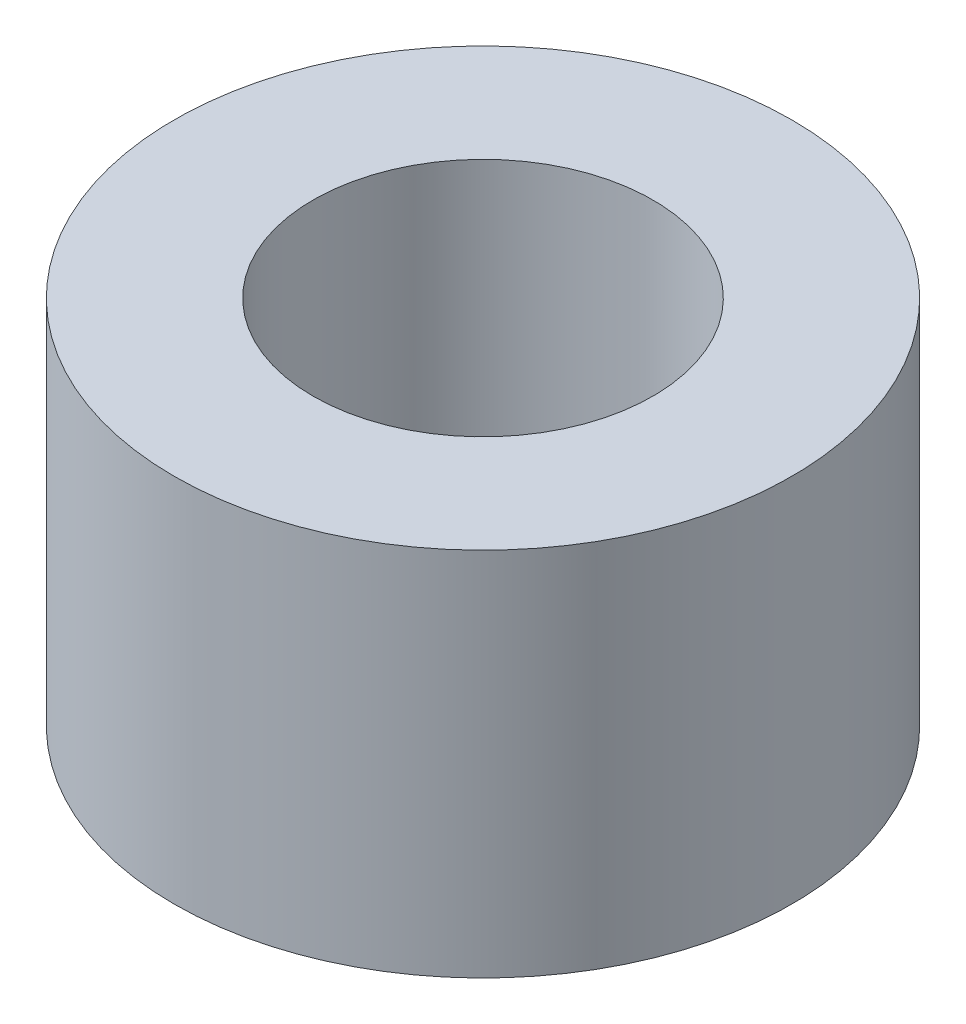
from build123d import *

# Parameters (mm, degrees)
SKETCH1_R           = 3.96875
SKETCH1_R_2         = 2.1844
BOSS_EXTRUDE1_DEPTH = 4.7625


with BuildPart() as part:
    # Sketch1 → Boss-Extrude1 (new body)
    with BuildSketch(Plane(origin=(0, 0, 0), x_dir=(1, 0, 0), z_dir=(0, 1, 0))):
        Circle(SKETCH1_R)
        Circle(SKETCH1_R_2, mode=Mode.SUBTRACT)
    extrude(amount=BOSS_EXTRUDE1_DEPTH)


solid = part.part
